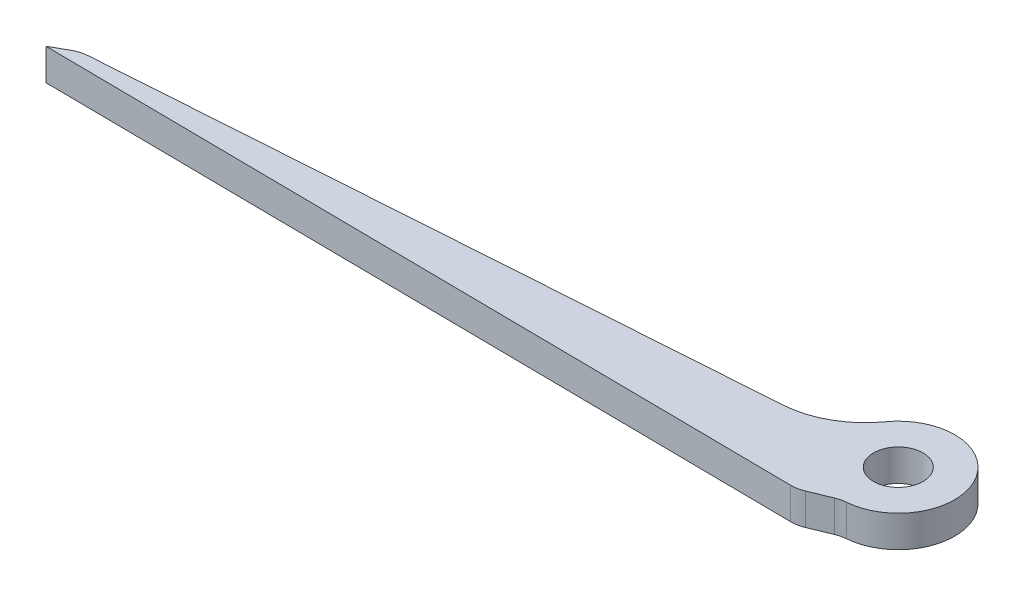
from build123d import *

# Parameters (mm, degrees)
SKETCH1_R           = 2.4892
BOSS_EXTRUDE1_DEPTH = 3.175
FILLET1_R           = 3.175
FILLET2_R           = 8.89


with BuildPart() as part:
    # Sketch1 → Boss-Extrude1 (new body)
    with BuildSketch(Plane(origin=(0, 0, 0), x_dir=(1, 0, 0), z_dir=(0, 1, 0))):
        with BuildLine():
            Line((-5.6642, 0), (-77.17919455, -4.935559597))
            Line((-77.17919455, -4.935559597), (-79.392042792, -6.182516957))
            Line((-79.392042792, -6.182516957), (-3.192042792, -6.978381463))
            Line((-3.192042792, -6.978381463), (0, -5.6642))
            ThreePointArc((0, -5.6642), (4.00519423, 4.00519423), (-5.6642, 0))
        make_face()
        Circle(SKETCH1_R, mode=Mode.SUBTRACT)
    extrude(amount=BOSS_EXTRUDE1_DEPTH)

    # Fillet1
    fillet1_edges = [part.edges().sort_by_distance(p)[0] for p in [
        (0, 1.5875, 5.6642),
        (-3.192042792, 1.5875, 6.978381463),
        (-77.17919455, 1.5875, 4.935559597),
    ]]
    fillet(fillet1_edges, radius=FILLET1_R)

    # Fillet2
    fillet2_edges = [part.edges().sort_by_distance(p)[0] for p in [
        (-5.6642, 1.5875, 0),
    ]]
    fillet(fillet2_edges, radius=FILLET2_R)


solid = part.part
